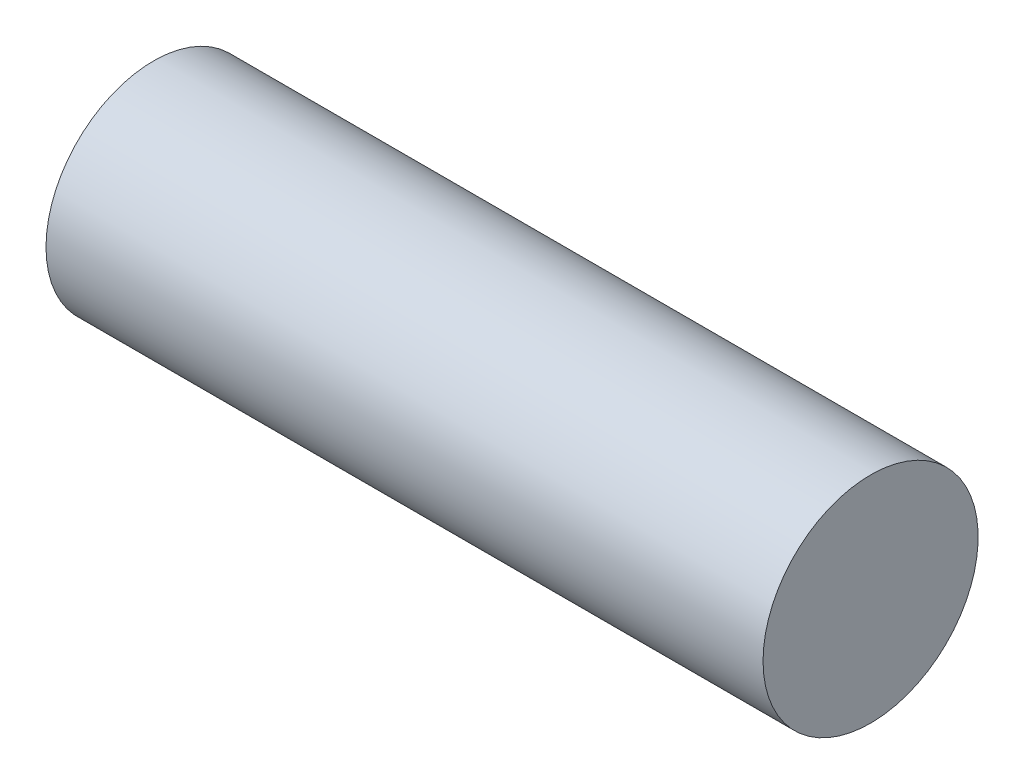
from build123d import *

# Parameters (mm, degrees)
SCHIZZO1_W = 40
SCHIZZO1_H = 6


with BuildPart() as part:
    # Schizzo1 → Rivoluzione1 (revolve)
    with BuildSketch(Plane.XY):
        with Locations((20, 3)):
            Rectangle(SCHIZZO1_W, SCHIZZO1_H)
    revolve(axis=Axis((0, 6, 0), (1, 0, 0)))


solid = part.part
